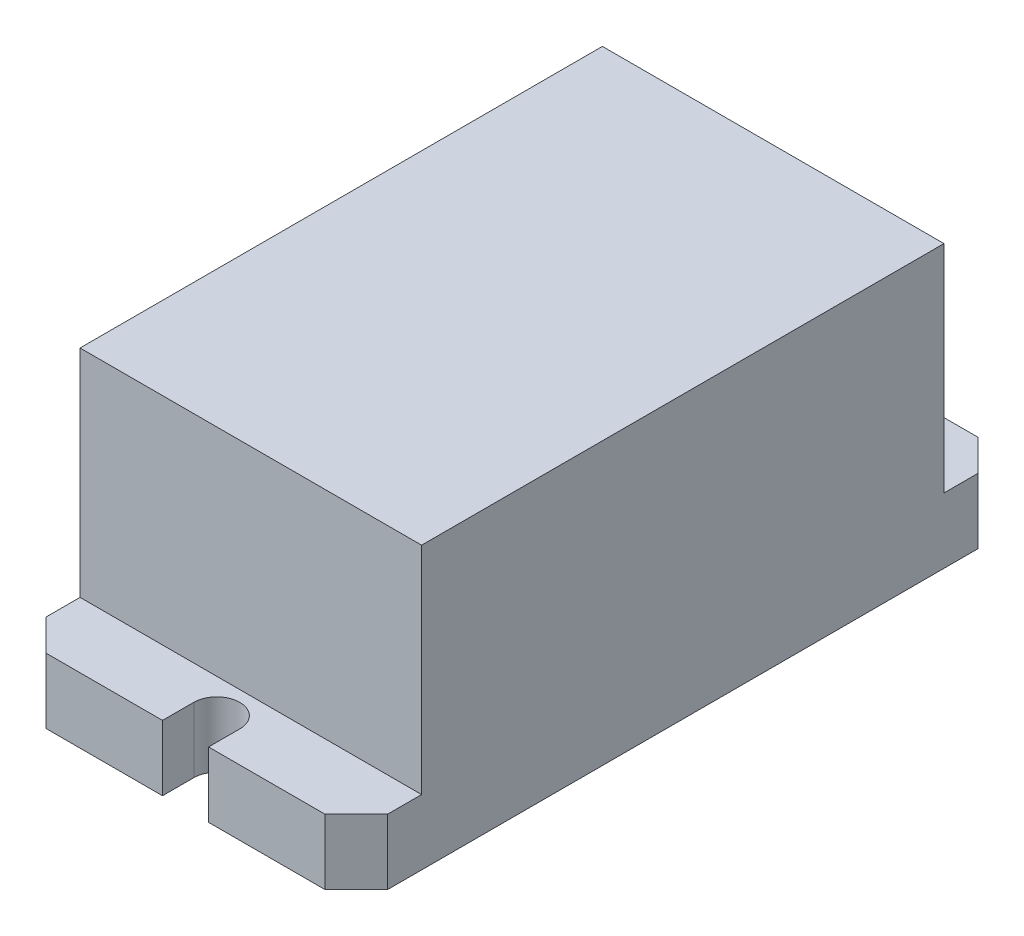
from build123d import *

# Parameters (mm, degrees)
SKETCH1_W           = 21.59
SKETCH1_H           = 33.02
BOSS_EXTRUDE1_DEPTH = 35.56
BOSS_EXTRUDE2_DEPTH = 8.255


with BuildPart() as part:
    # Sketch1 → Boss-Extrude1 (new body)
    with BuildSketch(Plane(origin=(0, 0, 0), x_dir=(1, 0, 0), z_dir=(0, 1, 0))):
        with Locations((-10.795, 16.51)):
            Rectangle(SKETCH1_W, SKETCH1_H)
    extrude(amount=BOSS_EXTRUDE1_DEPTH)

    # Sketch1_3 → Boss-Extrude2 (add)
    with BuildSketch(Plane(origin=(0, 0, 0), x_dir=(1, 0, 0), z_dir=(0, 1, 0))):
        with BuildLine():
            Line((-21.59, 33.02), (0, 33.02))
            Line((0, 33.02), (0, 34.414061598))
            ThreePointArc((0, 34.414061598), (-2.057519513, 35.266314085), (-2.909772, 37.323833597))
            Line((-2.909772, 37.323833597), (-2.909772, 41.275))
            Line((-2.909772, 41.275), (-17.638833597, 41.275))
            Line((-17.638833597, 41.275), (-21.59, 37.323833597))
            Line((-21.59, 37.323833597), (-21.59, 33.02))
        make_face()
    extrude(amount=BOSS_EXTRUDE2_DEPTH)

    # Mirror1: part across plane


with BuildPart() as part_1:
    add(part.part)
    add(part.part.mirror(Plane(origin=(0, 35.56, 0), x_dir=(1, 0, 0), z_dir=(0, 0, 1))))

    # Mirror2: part across plane


with BuildPart() as part_2:
    add(part_1.part)
    add(part_1.part.mirror(Plane(origin=(0, 35.56, 0), x_dir=(0, 0, 1), z_dir=(-1, 0, 0))))


solid = part_2.part
